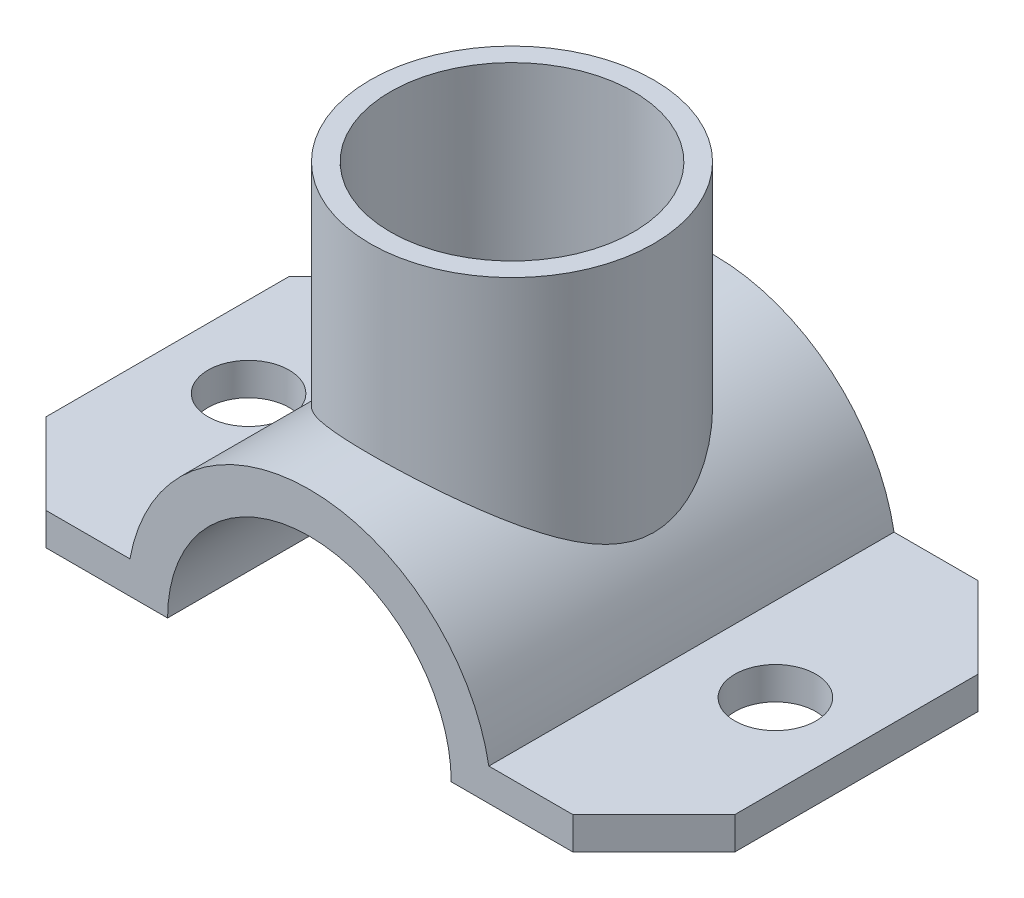
from build123d import *

# Parameters (mm, degrees)
BOSS_EXTRUDE1_DEPTH = 25
CHAMFER1_SIZE       = 10
SKETCH2_R           = 5
CUT_EXTRUDE1_DEPTH  = 50
BOSS_EXTRUDE2_REACH = 47
SKETCH3_R           = 17.5
SKETCH3_R_2         = 15
SKETCH4_R           = 7.5
CUT_EXTRUDE2_DEPTH  = 50


with BuildPart() as part:
    # Sketch1 → Boss-Extrude1 (new body, symmetric)
    with BuildSketch(Plane.XY):
        with BuildLine():
            Line((-17.5, 0), (-42.5, 0))
            Line((-42.5, 0), (-42.5, 4))
            Line((-42.5, 4), (-22.141589825, 4))
            ThreePointArc((-22.141589825, 4), (0, 22.5), (22.141589825, 4))
            Line((22.141589825, 4), (42.5, 4))
            Line((42.5, 4), (42.5, 0))
            Line((42.5, 0), (17.5, 0))
            ThreePointArc((17.5, 0), (0, 17.5), (-17.5, 0))
        make_face()
    extrude(amount=BOSS_EXTRUDE1_DEPTH, both=True)

    # Chamfer1
    chamfer1_edges = [part.edges().sort_by_distance(p)[0] for p in [
        (-42.5, 2, 25),
        (42.5, 2, 25),
        (42.5, 2, -25),
        (-42.5, 2, -25),
    ]]
    chamfer(chamfer1_edges, length=CHAMFER1_SIZE)

    # Sketch2 → Cut-Extrude1 (cut)
    with BuildSketch(Plane(origin=(0, 4, 0), x_dir=(1, 0, 0), z_dir=(0, 1, 0))):
        with Locations((32.5, 0)):
            Circle(SKETCH2_R)
        with Locations((-32.5, 0)):
            Circle(SKETCH2_R)
    extrude(amount=-CUT_EXTRUDE1_DEPTH, mode=Mode.SUBTRACT)

    # Sketch3 → Boss-Extrude2 (add, up to next)
    with BuildSketch(Plane(origin=(0, 45, 0), x_dir=(1, 0, 0), z_dir=(0, 1, 0)), mode=Mode.PRIVATE) as boss_extrude2_sk1:
        Circle(SKETCH3_R)
        Circle(SKETCH3_R_2, mode=Mode.SUBTRACT)
    boss_extrude2_tool1 = extrude(boss_extrude2_sk1.sketch, amount=-BOSS_EXTRUDE2_REACH, mode=Mode.PRIVATE) - part.part
    add(boss_extrude2_tool1.solids().sort_by_distance((-17.005025, 45, 0))[0])

    # Sketch4 → Cut-Extrude2 (cut)
    with BuildSketch(Plane(origin=(0, 45, 0), x_dir=(1, 0, 0), z_dir=(0, 1, 0))):
        Circle(SKETCH4_R)
    extrude(amount=-CUT_EXTRUDE2_DEPTH, mode=Mode.SUBTRACT)


solid = part.part
